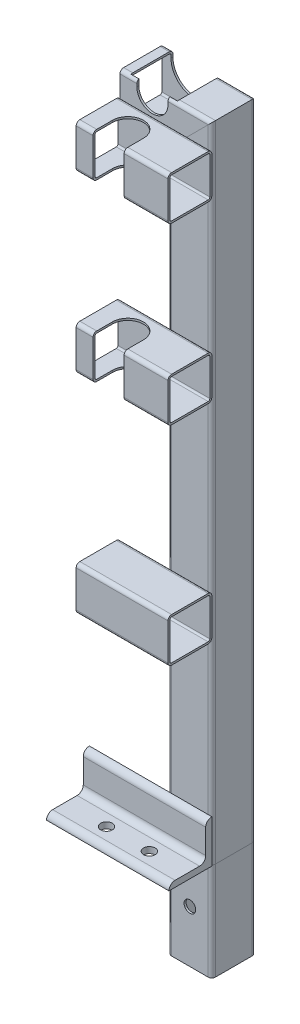
from build123d import *

# Parameters (mm, degrees)
STRUCTURAL_MEMBERMAIN_DEPTH        = 1
STRUCTURAL_MEMBERMAIN_DEPTH_BACK   = 80
STRUCTURAL_MEMBERMAIN_2_DEPTH      = 535.314422766
STRUCTURAL_MEMBERMAIN_3_DEPTH      = 83.414422766
CUT_EXTRUDETOPRAILGUIDE_DEPTH      = 574.675404737
CUT_EXTRUDETOPRAILGUIDE_DEPTH_BACK = 574.675404737
STRUCTURAL_MEMBERANGLE_DEPTH       = 100
SKETCH15_R                         = 4.7625
CUT_EXTRUDEMOUNTINGHOLES_DEPTH     = 576.831112393
CUT_EXTRUDEENLARGERAILGUIDE_START  = -17.9
CUT_EXTRUDEENLARGERAILGUIDE_DEPTH  = 34.2
STRUCTURAL_MEMBER1_DEPTH           = 75
STRUCTURAL_MEMBER1_2_DEPTH         = 75
STRUCTURAL_MEMBER1_3_DEPTH         = 75
CUT_EXTRUDE1_DEPTH                 = 633.190588351
SKETCH21_R                         = 4.7625
CUT_EXTRUDE2_DEPTH                 = 575.512576016


with BuildPart() as part:
    # Sketch11 → Structural MemberMain (new, two sides)
    with BuildSketch(Plane(origin=(210.6, 0, 0), x_dir=(-1, 0, 0), z_dir=(0, 1, 0))) as structural_membermain_sk:
        with BuildLine():
            Line((-14.9, 17.9), (14.9, 17.9))
            ThreePointArc((14.9, 17.9), (17.021320344, 17.021320344), (17.9, 14.9))
            Line((17.9, 14.9), (17.9, -14.9))
            ThreePointArc((17.9, -14.9), (17.021320344, -17.021320344), (14.9, -17.9))
            Line((14.9, -17.9), (-14.9, -17.9))
            ThreePointArc((-14.9, -17.9), (-17.021320344, -17.021320344), (-17.9, -14.9))
            Line((-17.9, -14.9), (-17.9, 14.9))
            ThreePointArc((-17.9, 14.9), (-17.021320344, 17.021320344), (-14.9, 17.9))
        make_face()
        with BuildLine():
            Line((-14.9, 16.3), (14.9, 16.3))
            ThreePointArc((14.9, 16.3), (15.889949494, 15.889949494), (16.3, 14.9))
            Line((16.3, 14.9), (16.3, -14.9))
            ThreePointArc((16.3, -14.9), (15.889949494, -15.889949494), (14.9, -16.3))
            Line((14.9, -16.3), (-14.9, -16.3))
            ThreePointArc((-14.9, -16.3), (-15.889949494, -15.889949494), (-16.3, -14.9))
            Line((-16.3, -14.9), (-16.3, 14.9))
            ThreePointArc((-16.3, 14.9), (-15.889949494, 15.889949494), (-14.9, 16.3))
        make_face(mode=Mode.SUBTRACT)
    extrude(amount=STRUCTURAL_MEMBERMAIN_DEPTH)
    extrude(structural_membermain_sk.sketch, amount=-STRUCTURAL_MEMBERMAIN_DEPTH_BACK)

    # Structural MemberMain mitre 1
    split(bisect_by=Plane(origin=(210.6, 0, 0), x_dir=(1, 0, 0), z_dir=(0, -1, 0)), keep=Keep.TOP)

    # Sketch21 → Cut-Extrude2 (cut, through all)
    with BuildSketch(Plane.XY.offset(17.9)):
        with Locations((210.6, -37.5)):
            Circle(SKETCH21_R)
    extrude(amount=-CUT_EXTRUDE2_DEPTH, mode=Mode.SUBTRACT)


with BuildPart() as body_2:
    # Sketch11 on segment 2 (carried to segment 2) → Structural MemberMain 2 (new body)
    with BuildSketch(Plane(origin=(210.6, -1, 0), x_dir=(-1, 0, 0), z_dir=(0, 1, 0))):
        with BuildLine():
            Line((-14.9, 17.9), (14.9, 17.9))
            ThreePointArc((14.9, 17.9), (17.021320344, 17.021320344), (17.9, 14.9))
            Line((17.9, 14.9), (17.9, -14.9))
            ThreePointArc((17.9, -14.9), (17.021320344, -17.021320344), (14.9, -17.9))
            Line((14.9, -17.9), (-14.9, -17.9))
            ThreePointArc((-14.9, -17.9), (-17.021320344, -17.021320344), (-17.9, -14.9))
            Line((-17.9, -14.9), (-17.9, 14.9))
            ThreePointArc((-17.9, 14.9), (-17.021320344, 17.021320344), (-14.9, 17.9))
        make_face()
        with BuildLine():
            Line((-14.9, 16.3), (14.9, 16.3))
            ThreePointArc((14.9, 16.3), (15.889949494, 15.889949494), (16.3, 14.9))
            Line((16.3, 14.9), (16.3, -14.9))
            ThreePointArc((16.3, -14.9), (15.889949494, -15.889949494), (14.9, -16.3))
            Line((14.9, -16.3), (-14.9, -16.3))
            ThreePointArc((-14.9, -16.3), (-15.889949494, -15.889949494), (-16.3, -14.9))
            Line((-16.3, -14.9), (-16.3, 14.9))
            ThreePointArc((-16.3, 14.9), (-15.889949494, 15.889949494), (-14.9, 16.3))
        make_face(mode=Mode.SUBTRACT)
    extrude(amount=STRUCTURAL_MEMBERMAIN_2_DEPTH)

    # Structural MemberMain 2 mitre 1
    split(bisect_by=Plane(origin=(210.6, 0, 0), x_dir=(-1, 0, 0), z_dir=(0, 1, 0)), keep=Keep.TOP)

    # Structural MemberMain 2 mitre 2
    split(bisect_by=Plane(origin=(210.6, 508, 0), x_dir=(0.707106781, 0.707106781, 0), z_dir=(0.707106781, -0.707106781, 0)), keep=Keep.TOP)


with BuildPart() as body_3:
    # Sketch11 on segment 3 (carried to segment 3) → Structural MemberMain 3 (new body)
    with BuildSketch(Plane(origin=(236.914422766, 508, 0), x_dir=(0, -1, 0), z_dir=(-1, 0, 0))):
        with BuildLine():
            Line((-14.9, 17.9), (14.9, 17.9))
            ThreePointArc((14.9, 17.9), (17.021320344, 17.021320344), (17.9, 14.9))
            Line((17.9, 14.9), (17.9, -14.9))
            ThreePointArc((17.9, -14.9), (17.021320344, -17.021320344), (14.9, -17.9))
            Line((14.9, -17.9), (-14.9, -17.9))
            ThreePointArc((-14.9, -17.9), (-17.021320344, -17.021320344), (-17.9, -14.9))
            Line((-17.9, -14.9), (-17.9, 14.9))
            ThreePointArc((-17.9, 14.9), (-17.021320344, 17.021320344), (-14.9, 17.9))
        make_face()
        with BuildLine():
            Line((-14.9, 16.3), (14.9, 16.3))
            ThreePointArc((14.9, 16.3), (15.889949494, 15.889949494), (16.3, 14.9))
            Line((16.3, 14.9), (16.3, -14.9))
            ThreePointArc((16.3, -14.9), (15.889949494, -15.889949494), (14.9, -16.3))
            Line((14.9, -16.3), (-14.9, -16.3))
            ThreePointArc((-14.9, -16.3), (-15.889949494, -15.889949494), (-16.3, -14.9))
            Line((-16.3, -14.9), (-16.3, 14.9))
            ThreePointArc((-16.3, 14.9), (-15.889949494, 15.889949494), (-14.9, 16.3))
        make_face(mode=Mode.SUBTRACT)
    extrude(amount=STRUCTURAL_MEMBERMAIN_3_DEPTH)

    # Structural MemberMain 3 mitre 1
    split(bisect_by=Plane(origin=(210.6, 508, 0), x_dir=(-0.707106781, -0.707106781, 0), z_dir=(-0.707106781, 0.707106781, 0)), keep=Keep.TOP)

    # Sketch12 → Cut-ExtrudeTopRailGuide (cut, two sides)
    with BuildSketch(Plane.XY) as cut_extrudetoprailguide_sk:
        with BuildLine():
            Line((167.3, 520.7), (167.3, 531.1))
            ThreePointArc((167.3, 531.1), (180, 543.8), (192.7, 531.1))
            Line((192.7, 531.1), (192.7, 520.7))
            ThreePointArc((192.7, 520.7), (180, 508), (167.3, 520.7))
        make_face()
    extrude(amount=CUT_EXTRUDETOPRAILGUIDE_DEPTH, mode=Mode.SUBTRACT)
    extrude(cut_extrudetoprailguide_sk.sketch, amount=-CUT_EXTRUDETOPRAILGUIDE_DEPTH_BACK, mode=Mode.SUBTRACT)

    # Sketch16 → Cut-ExtrudeEnlargeRailGuide (cut)
    with BuildSketch(Plane.XY.offset(CUT_EXTRUDEENLARGERAILGUIDE_START)):
        with BuildLine():
            Line((199.05, 520.7), (199.05, 531.1))
            ThreePointArc((199.05, 531.1), (180, 550.15), (160.95, 531.1))
            Line((160.95, 531.1), (160.95, 520.7))
            ThreePointArc((160.95, 520.7), (180, 501.65), (199.05, 520.7))
        make_face()
    extrude(amount=CUT_EXTRUDEENLARGERAILGUIDE_DEPTH, mode=Mode.SUBTRACT)


with BuildPart() as body_4:
    # Sketch14 → Structural MemberAngle (new body)
    with BuildSketch(Plane(origin=(128.5, 0, 17.9), x_dir=(0, 1, 0), z_dir=(1, 0, 0))):
        with BuildLine():
            Line((0, 0), (0, 35))
            ThreePointArc((0, 35), (3.535533906, 33.535533906), (5, 30))
            Line((5, 30), (5, 10))
            ThreePointArc((5, 10), (6.464466094, 6.464466094), (10, 5))
            Line((10, 5), (30, 5))
            ThreePointArc((30, 5), (33.535533906, 3.535533906), (35, 0))
            Line((35, 0), (0, 0))
        make_face()
    extrude(amount=STRUCTURAL_MEMBERANGLE_DEPTH)

    # Sketch15 → Cut-ExtrudeMountingHoles (cut, through all)
    with BuildSketch(Plane(origin=(0, 0, 0), x_dir=(1, 0, 0), z_dir=(0, 1, 0))):
        with Locations(Location((162.5, -37.9, 0), (0, 0, 90))):
            Circle(SKETCH15_R)
        with Locations(Location((197.5, -37.9, 0), (0, 0, 90))):
            Circle(SKETCH15_R)
    extrude(amount=CUT_EXTRUDEMOUNTINGHOLES_DEPTH, mode=Mode.SUBTRACT)


with BuildPart() as body_5:
    # Sketch19 → Structural Member1 (new body)
    with BuildSketch(Plane(origin=(228.5, 489.1, 35.8), x_dir=(0, -1, 0), z_dir=(-1, 0, 0))):
        with BuildLine():
            Line((-14.9, 17.9), (14.9, 17.9))
            ThreePointArc((14.9, 17.9), (17.021320344, 17.021320344), (17.9, 14.9))
            Line((17.9, 14.9), (17.9, -14.9))
            ThreePointArc((17.9, -14.9), (17.021320344, -17.021320344), (14.9, -17.9))
            Line((14.9, -17.9), (-14.9, -17.9))
            ThreePointArc((-14.9, -17.9), (-17.021320344, -17.021320344), (-17.9, -14.9))
            Line((-17.9, -14.9), (-17.9, 14.9))
            ThreePointArc((-17.9, 14.9), (-17.021320344, 17.021320344), (-14.9, 17.9))
        make_face()
        with BuildLine():
            Line((-14.9, 16.3), (14.9, 16.3))
            ThreePointArc((14.9, 16.3), (15.889949494, 15.889949494), (16.3, 14.9))
            Line((16.3, 14.9), (16.3, -14.9))
            ThreePointArc((16.3, -14.9), (15.889949494, -15.889949494), (14.9, -16.3))
            Line((14.9, -16.3), (-14.9, -16.3))
            ThreePointArc((-14.9, -16.3), (-15.889949494, -15.889949494), (-16.3, -14.9))
            Line((-16.3, -14.9), (-16.3, 14.9))
            ThreePointArc((-16.3, 14.9), (-15.889949494, 15.889949494), (-14.9, 16.3))
        make_face(mode=Mode.SUBTRACT)
    extrude(amount=STRUCTURAL_MEMBER1_DEPTH)


with BuildPart() as body_6:
    # Sketch19 on segment 2 (carried to segment 2) → Structural Member1 2 (new body)
    with BuildSketch(Plane(origin=(228.5, 176.5, 35.8), x_dir=(0, -1, 0), z_dir=(-1, 0, 0))):
        with BuildLine():
            Line((-14.9, 17.9), (14.9, 17.9))
            ThreePointArc((14.9, 17.9), (17.021320344, 17.021320344), (17.9, 14.9))
            Line((17.9, 14.9), (17.9, -14.9))
            ThreePointArc((17.9, -14.9), (17.021320344, -17.021320344), (14.9, -17.9))
            Line((14.9, -17.9), (-14.9, -17.9))
            ThreePointArc((-14.9, -17.9), (-17.021320344, -17.021320344), (-17.9, -14.9))
            Line((-17.9, -14.9), (-17.9, 14.9))
            ThreePointArc((-17.9, 14.9), (-17.021320344, 17.021320344), (-14.9, 17.9))
        make_face()
        with BuildLine():
            Line((-14.9, 16.3), (14.9, 16.3))
            ThreePointArc((14.9, 16.3), (15.889949494, 15.889949494), (16.3, 14.9))
            Line((16.3, 14.9), (16.3, -14.9))
            ThreePointArc((16.3, -14.9), (15.889949494, -15.889949494), (14.9, -16.3))
            Line((14.9, -16.3), (-14.9, -16.3))
            ThreePointArc((-14.9, -16.3), (-15.889949494, -15.889949494), (-16.3, -14.9))
            Line((-16.3, -14.9), (-16.3, 14.9))
            ThreePointArc((-16.3, 14.9), (-15.889949494, 15.889949494), (-14.9, 16.3))
        make_face(mode=Mode.SUBTRACT)
    extrude(amount=STRUCTURAL_MEMBER1_2_DEPTH)


with BuildPart() as body_7:
    # Sketch19 on segment 3 (carried to segment 3) → Structural Member1 3 (new body)
    with BuildSketch(Plane(origin=(228.5, 346.5, 35.8), x_dir=(0, -1, 0), z_dir=(-1, 0, 0))):
        with BuildLine():
            Line((-14.9, 17.9), (14.9, 17.9))
            ThreePointArc((14.9, 17.9), (17.021320344, 17.021320344), (17.9, 14.9))
            Line((17.9, 14.9), (17.9, -14.9))
            ThreePointArc((17.9, -14.9), (17.021320344, -17.021320344), (14.9, -17.9))
            Line((14.9, -17.9), (-14.9, -17.9))
            ThreePointArc((-14.9, -17.9), (-17.021320344, -17.021320344), (-17.9, -14.9))
            Line((-17.9, -14.9), (-17.9, 14.9))
            ThreePointArc((-17.9, 14.9), (-17.021320344, 17.021320344), (-14.9, 17.9))
        make_face()
        with BuildLine():
            Line((-14.9, 16.3), (14.9, 16.3))
            ThreePointArc((14.9, 16.3), (15.889949494, 15.889949494), (16.3, 14.9))
            Line((16.3, 14.9), (16.3, -14.9))
            ThreePointArc((16.3, -14.9), (15.889949494, -15.889949494), (14.9, -16.3))
            Line((14.9, -16.3), (-14.9, -16.3))
            ThreePointArc((-14.9, -16.3), (-15.889949494, -15.889949494), (-16.3, -14.9))
            Line((-16.3, -14.9), (-16.3, 14.9))
            ThreePointArc((-16.3, 14.9), (-15.889949494, 15.889949494), (-14.9, 16.3))
        make_face(mode=Mode.SUBTRACT)
    extrude(amount=STRUCTURAL_MEMBER1_3_DEPTH)


with BuildPart() as cut_extrude1_tool:
    # Sketch20 → Cut-Extrude1 (new, through all)
    with BuildSketch(Plane(origin=(0, 507, 0), x_dir=(1, 0, 0), z_dir=(0, 1, 0))):
        with BuildLine():
            Line((192.7, -37.9), (192.7, -70.768771396))
            ThreePointArc((192.7, -70.768771396), (180, -83.468771396), (167.3, -70.768771396))
            Line((167.3, -70.768771396), (167.3, -37.9))
            ThreePointArc((167.3, -37.9), (180, -25.2), (192.7, -37.9))
        make_face()
    extrude(amount=-CUT_EXTRUDE1_DEPTH)


with BuildPart() as body_5_1:
    add(body_5.part)

    # Cut-Extrude1: cut by cut_extrude1_tool
    add(cut_extrude1_tool.part, mode=Mode.SUBTRACT)


with BuildPart() as body_7_1:
    add(body_7.part)

    # Cut-Extrude1: cut by cut_extrude1_tool
    add(cut_extrude1_tool.part, mode=Mode.SUBTRACT)


solid = Compound([part.part, body_2.part, body_3.part, body_4.part, body_6.part, body_5_1.part, body_7_1.part])
